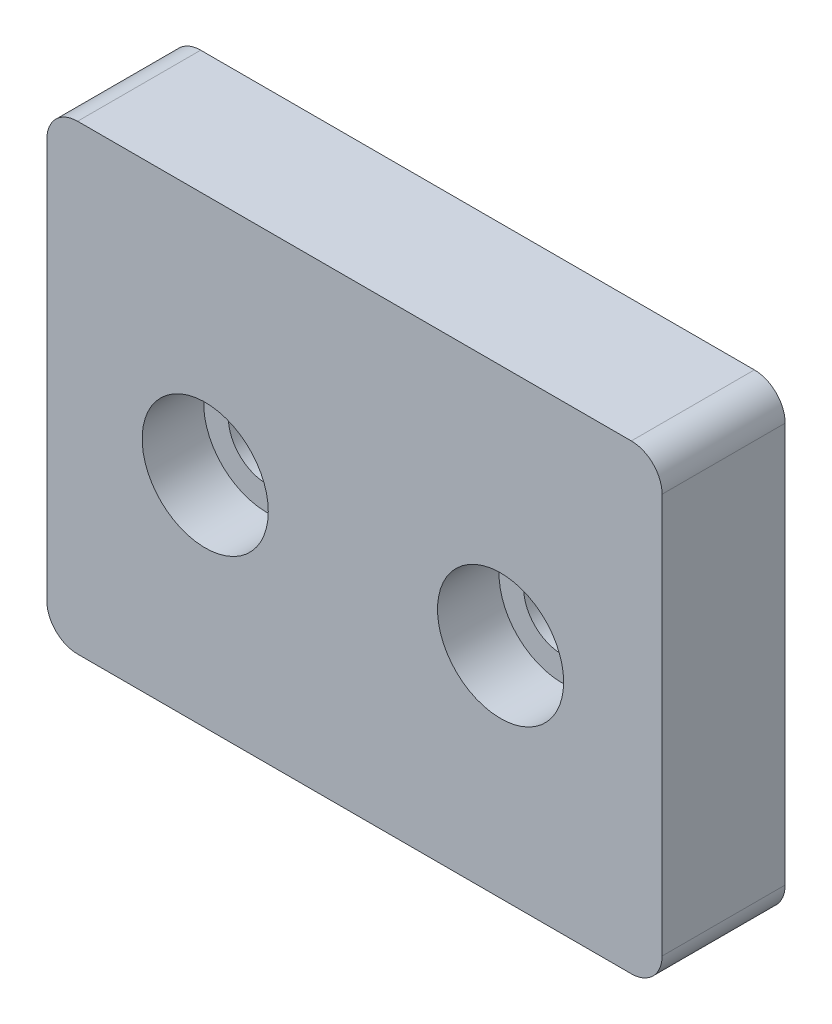
from build123d import *

# Parameters (mm, degrees)
SKETCH1_W           = 19.997483178
SKETCH1_H           = 15
SKETCH1_R           = 1.25
BOSS_EXTRUDE1_DEPTH = 4
SKETCH2_R           = 2.05
CUT_EXTRUDE1_DEPTH  = 2
FILLET1_R           = 1


with BuildPart() as part:
    # Sketch1 → Boss-Extrude1 (new body)
    with BuildSketch(Plane.XY):
        with Locations((0, -0.854350343)):
            Rectangle(SKETCH1_W, SKETCH1_H)
        with Locations((-4.851258411, -1.24229421)):
            Circle(SKETCH1_R, mode=Mode.SUBTRACT)
        with Locations((4.748741589, -1.24229421)):
            Circle(SKETCH1_R, mode=Mode.SUBTRACT)
    extrude(amount=BOSS_EXTRUDE1_DEPTH)

    # Sketch2 → Cut-Extrude1 (cut)
    with BuildSketch(Plane.XY.offset(4)):
        with Locations((-4.851258411, -1.24229421)):
            Circle(SKETCH2_R)
        with Locations((4.748741589, -1.24229421)):
            Circle(SKETCH2_R)
    extrude(amount=-CUT_EXTRUDE1_DEPTH, mode=Mode.SUBTRACT)

    # Fillet1
    fillet1_edges = [part.edges().sort_by_distance(p)[0] for p in [
        (9.998741589, -8.354350343, 2),
        (-9.998741589, -8.354350343, 2),
        (-9.998741589, 6.645649657, 2),
        (9.998741589, 6.645649657, 2),
    ]]
    fillet(fillet1_edges, radius=FILLET1_R)


solid = part.part
